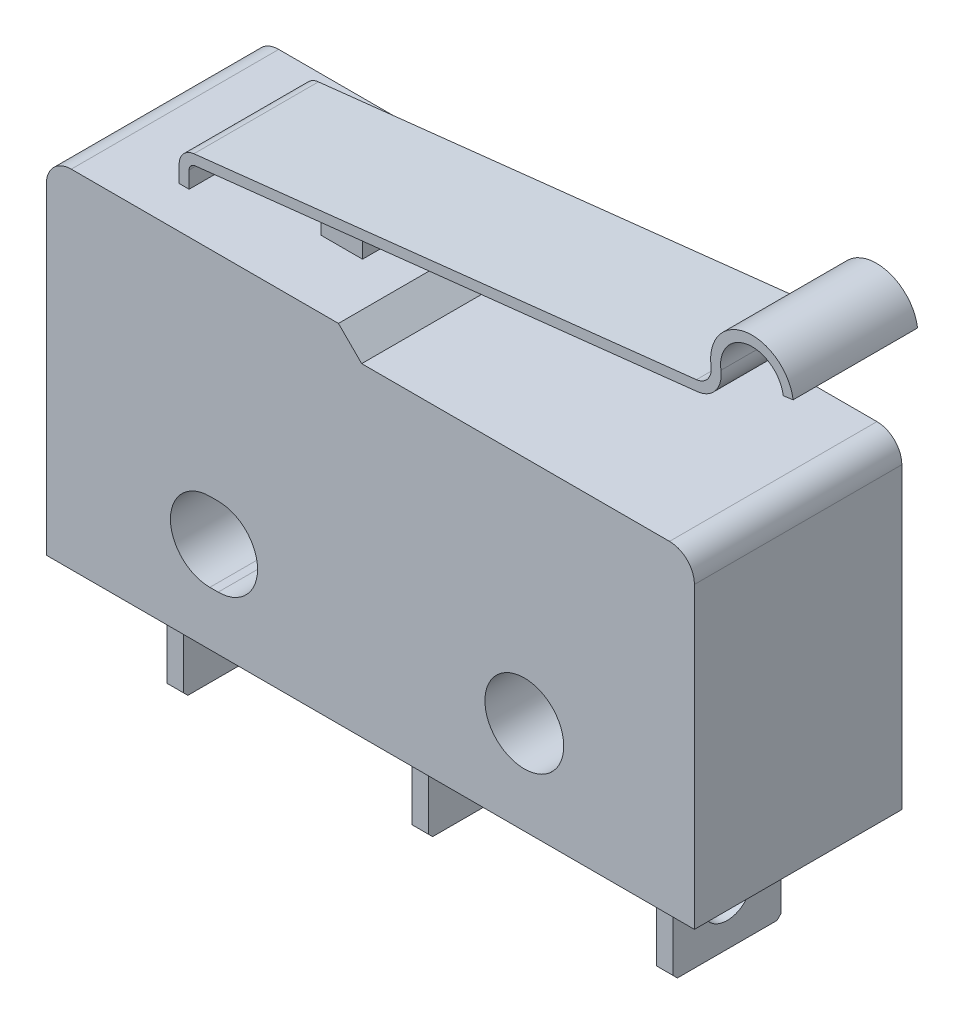
from build123d import *

# Parameters (mm, degrees)
SKETCH2_R           = 1.2065
EXTRUDE1_DEPTH      = 3.175
EXTRUDE2_DEPTH      = 1.1049
SKETCH10_R          = 0.762
EXTRUDE6_DEPTH      = 0.254
LPATTERN1_COUNT     = 3
LPATTERN1_PITCH     = 7.493
EXTRUDE_THIN1_DEPTH = 1.905


with BuildPart() as part:
    # Sketch2 → Extrude1 (new body, symmetric)
    with BuildSketch(Plane.XY):
        with BuildLine():
            Line((-9.1567, 10.6172), (-4.9149, 10.6172))
            Line((-4.9149, 10.6172), (-0.9779, 10.6172))
            Line((-0.9779, 10.6172), (-0.2667, 9.906))
            Line((-0.2667, 9.906), (9.1567, 9.906))
            ThreePointArc((9.1567, 9.906), (9.695515367, 9.682815367), (9.9187, 9.144))
            Line((9.9187, 9.144), (9.9187, 0))
            Line((9.9187, 0), (-9.9187, 0))
            Line((-9.9187, 0), (-9.9187, 9.8552))
            ThreePointArc((-9.9187, 9.8552), (-9.695515367, 10.394015367), (-9.1567, 10.6172))
        make_face()
        with Locations((4.7117, 2.8575)):
            Circle(SKETCH2_R, mode=Mode.SUBTRACT)
        with BuildLine():
            Line((-4.9149, 4.064), (-4.6609, 4.064))
            ThreePointArc((-4.6609, 4.064), (-3.4544, 2.8575), (-4.6609, 1.651))
            Line((-4.6609, 1.651), (-4.9149, 1.651))
            ThreePointArc((-4.9149, 1.651), (-6.1214, 2.8575), (-4.9149, 4.064))
        make_face(mode=Mode.SUBTRACT)
    extrude(amount=EXTRUDE1_DEPTH, both=True)

    # Sketch10 → Extrude6 (add, symmetric)
    with BuildSketch(Plane(origin=(-7.493, 0, 0), x_dir=(0, 0, -1), z_dir=(1, 0, 0))):
        Polygon((-1.651, 0), (-1.651, -3.0734), (-1.524, -3.2004), (1.524, -3.2004), (1.651, -3.0734), (1.651, 0), align=None)
        with Locations((0, -1.6764)):
            Circle(SKETCH10_R, mode=Mode.SUBTRACT)
    extrude6 = extrude(amount=EXTRUDE6_DEPTH, both=True)

    # LPattern1: Extrude6 ×3
    with Locations(*[(i * LPATTERN1_PITCH, 0, 0) for i in range(1, LPATTERN1_COUNT)]):
        add(extrude6)



with BuildPart() as body_2:
    # Sketch3 → Extrude2 (new body, symmetric)
    with BuildSketch(Plane.XY):
        with BuildLine():
            Line((-3.5814, 10.6172), (-3.5814, 11.524614746))
            ThreePointArc((-3.5814, 11.524614746), (-2.9464, 11.7475), (-2.3114, 11.524614746))
            Line((-2.3114, 11.524614746), (-2.3114, 10.6172))
            Line((-2.3114, 10.6172), (-3.5814, 10.6172))
        make_face()
    extrude(amount=EXTRUDE2_DEPTH, both=True)


with BuildPart() as part_1:
    add(part.part)

    add(body_2.part)  # Extrude-Thin1 merges body 2
    # Sketch11 → Extrude-Thin1 (add, symmetric)
    with BuildSketch(Plane.XY):
        with BuildLine():
            Line((-7.1247, 10.6172), (-7.1247, 11.128280087))
            ThreePointArc((-7.1247, 11.128280087), (-6.995143389, 11.467167386), (-6.672555901, 11.6332))
            Line((-6.672555901, 11.6332), (8.711185108, 13.335))
            ThreePointArc((8.711185108, 13.335), (9.057341476, 13.529355692), (9.157991006, 13.913371366))
            ThreePointArc((9.157991006, 13.913371366), (10.231016869, 15.353654497), (11.6713, 14.280628634))
            Line((11.6713, 14.280628634), (11.369702921, 14.236557762))
            ThreePointArc((11.369702921, 14.236557762), (10.275087741, 15.052057418), (9.459588085, 13.957442238))
            ThreePointArc((9.459588085, 13.957442238), (9.298548838, 13.343017159), (8.744698648, 13.032048052))
            Line((8.744698648, 13.032048052), (-6.63904236, 11.330248052))
            ThreePointArc((-6.63904236, 11.330248052), (-6.768077356, 11.263835007), (-6.8199, 11.128280087))
            Line((-6.8199, 11.128280087), (-6.8199, 10.6172))
            Line((-6.8199, 10.6172), (-7.1247, 10.6172))
        make_face()
    extrude(amount=EXTRUDE_THIN1_DEPTH, both=True)


solid = part_1.part
